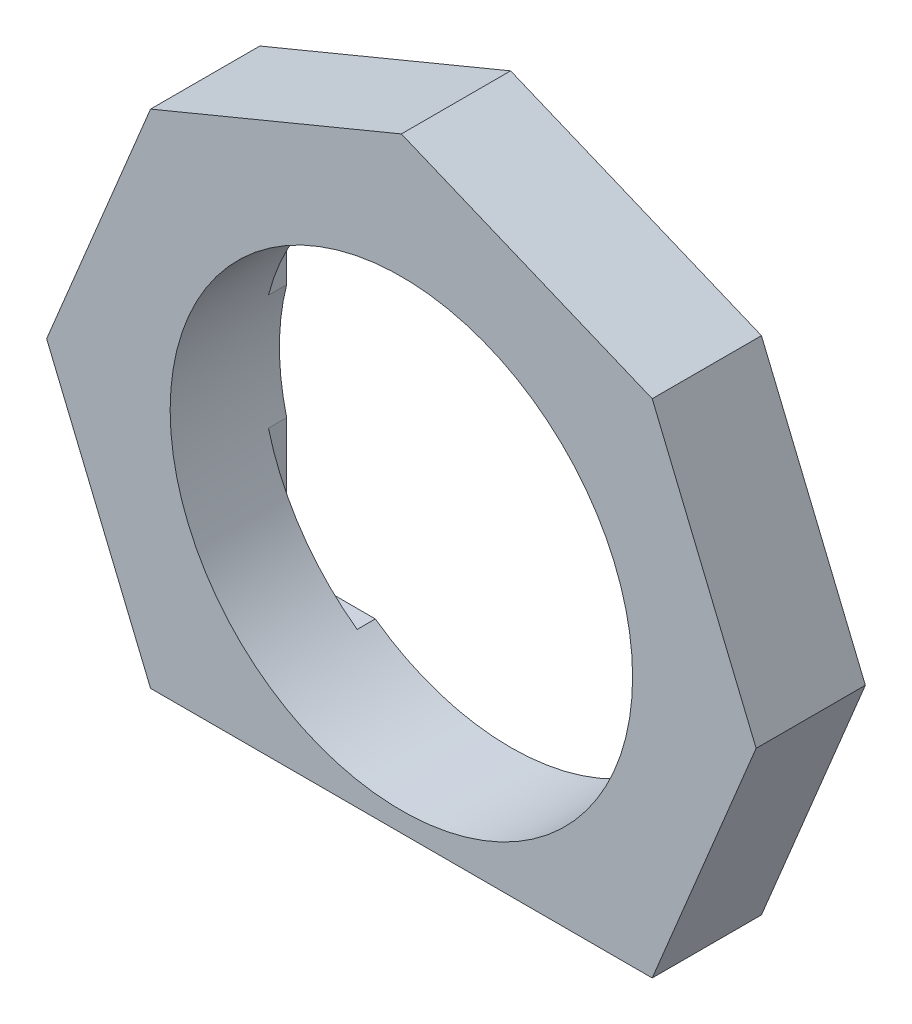
from build123d import *

# Parameters (mm, degrees)
BOSS_EXTRUDE1_DEPTH     = 3
SKETCH4_W               = 12.3
SKETCH4_H               = 10.3
CUT_EXTRUDE2_DEPTH      = 0.5
FILLET1_R               = 0.5
F_1_2_20_TAPPED_HOLE1_D = 12.7
CUT_EXTRUDE3_REACH      = 5


with BuildPart() as part:
    # Sketch2 → Boss-Extrude1 (new body)
    with BuildSketch(Plane.XY):
        Polygon((0, 9.741529803), (-6.888301783, 6.888301783), (-9.741529803, 0), (-6.888301783, -6.888301783), (0, -9.741529803), (6.888301783, -6.888301783), (9.741529803, 0), (6.888301783, 6.888301783), align=None)
    extrude(amount=BOSS_EXTRUDE1_DEPTH)

    # Sketch4 → Cut-Extrude2 (cut)
    with BuildSketch(Plane(origin=(0, 0, 0), x_dir=(-1, 0, 0), z_dir=(0, 0, -1))):
        Rectangle(SKETCH4_W, SKETCH4_H)
    extrude(amount=-CUT_EXTRUDE2_DEPTH, mode=Mode.SUBTRACT)

    # Fillet1
    fillet1_edges = [part.edges().sort_by_distance(p)[0] for p in [
        (-6.15, 5.15, 0.25),
        (-6.15, -5.15, 0.25),
        (6.15, -5.15, 0.25),
        (6.15, 5.15, 0.25),
    ]]
    fillet(fillet1_edges, radius=FILLET1_R)

    # 1/2-20 Tapped Hole1 (through all)
    with Locations(Plane.XY.offset(3)):
        with Locations((0, 0)):
            Hole(F_1_2_20_TAPPED_HOLE1_D / 2)

    # Sketch7 → Cut-Extrude3 (cut, up to next)
    with BuildSketch(Plane(origin=(0, 0, 0), x_dir=(-1, 0, 0), z_dir=(0, 0, -1)), mode=Mode.PRIVATE) as cut_extrude3_sk1:
        Polygon((-6.888301783, -6.888301783), (6.888301783, -6.888301783), (0, -9.741529803), align=None)
    cut_extrude3_tool1 = extrude(cut_extrude3_sk1.sketch, amount=-CUT_EXTRUDE3_REACH, mode=Mode.PRIVATE) & part.part
    add(cut_extrude3_tool1.solids().sort_by_distance((0, -7.839378, 0))[0], mode=Mode.SUBTRACT)


solid = part.part
